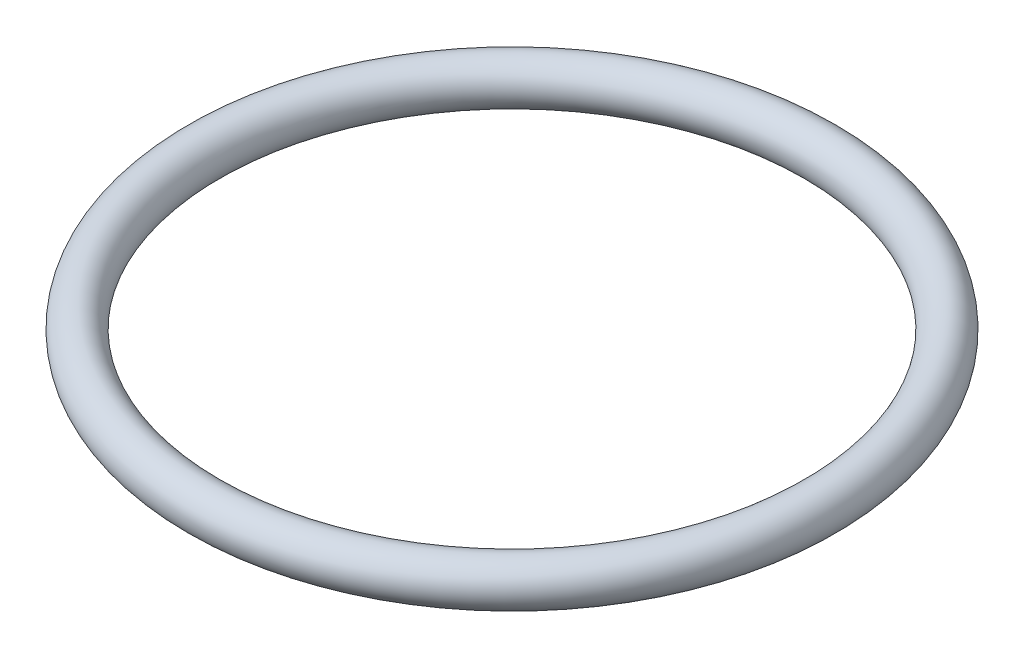
from build123d import *

# Parameters (mm, degrees)
SKETCH2_R = 12.5


with BuildPart() as part:
    # Sketch2 → Revolve1 (revolve)
    with BuildSketch(Plane(origin=(0, 0, 0), x_dir=(0, 0, -1), z_dir=(1, 0, 0))):
        with Locations((175, 0)):
            Circle(SKETCH2_R)
    revolve(axis=Axis((0, 0, 0), (0, 1, 0)))


solid = part.part
